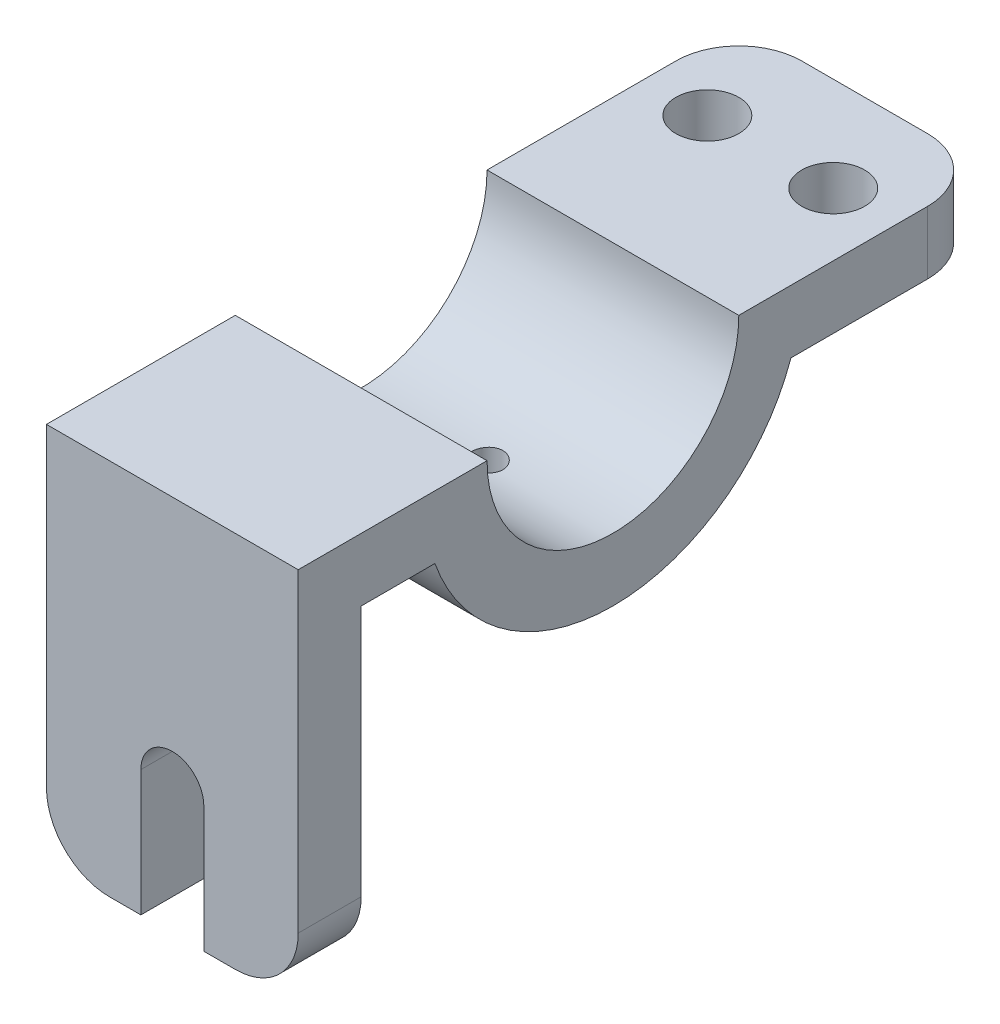
from build123d import *

# Parameters (mm, degrees)
BOSS_EXTRUDE1_DEPTH = 50.8
CUT_EXTRUDE1_DEPTH  = 22.86
CUT_EXTRUDE2_DEPTH  = 22.86
CUT_EXTRUDE3_DEPTH  = 22.86
SKETCH6_R           = 3.175
CUT_EXTRUDE4_DEPTH  = 60.96
CUT_EXTRUDE5_DEPTH  = 30.48
CUT_EXTRUDE6_DEPTH  = 30.48
SKETCH10_R          = 6.35
CUT_EXTRUDE7_DEPTH  = 30.48


with BuildPart() as part:
    # Sketch2 → Boss-Extrude1 (new body)
    with BuildSketch(Plane(origin=(0, 0, 0), x_dir=(0, 0, -1), z_dir=(1, 0, 0))):
        with BuildLine():
            Line((0, 0), (38.1, 0))
            ThreePointArc((38.1, 0), (63.5, -25.4), (88.9, 0))
            Line((88.9, 0), (139.7, 0))
            Line((139.7, 0), (139.7, -12.7))
            Line((139.7, -12.7), (99.421024484, -12.7))
            ThreePointArc((99.421024484, -12.7), (63.5, -38.1), (27.578975516, -12.7))
            Line((27.578975516, -12.7), (12.7, -12.7))
            Line((12.7, -12.7), (12.7, -76.2))
            Line((12.7, -76.2), (0, -76.2))
            Line((0, -76.2), (0, 0))
        make_face()
    extrude(amount=BOSS_EXTRUDE1_DEPTH)

    # Sketch3 → Cut-Extrude1 (cut)
    with BuildSketch(Plane.XY):
        with BuildLine():
            Line((50.8, -63.5), (50.8, -76.2))
            Line((50.8, -76.2), (38.1, -76.2))
            ThreePointArc((38.1, -76.2), (47.080256121, -72.480256121), (50.8, -63.5))
        make_face()
    extrude(amount=-CUT_EXTRUDE1_DEPTH, mode=Mode.SUBTRACT)

    # Sketch4 → Cut-Extrude2 (cut)
    with BuildSketch(Plane.XY):
        with BuildLine():
            Line((0, -63.5), (0, -76.2))
            Line((0, -76.2), (12.7, -76.2))
            ThreePointArc((12.7, -76.2), (3.719743879, -72.480256121), (0, -63.5))
        make_face()
    extrude(amount=-CUT_EXTRUDE2_DEPTH, mode=Mode.SUBTRACT)

    # Sketch5 → Cut-Extrude3 (cut)
    with BuildSketch(Plane.XY):
        with BuildLine():
            Line((19.05, -76.2), (19.05, -50.8))
            ThreePointArc((19.05, -50.8), (25.4, -44.45), (31.75, -50.8))
            Line((31.75, -50.8), (31.75, -76.2))
            Line((31.75, -76.2), (19.05, -76.2))
        make_face()
    extrude(amount=-CUT_EXTRUDE3_DEPTH, mode=Mode.SUBTRACT)

    # Sketch6 → Cut-Extrude4 (cut)
    with BuildSketch(Plane(origin=(0, 0, 0), x_dir=(1, 0, 0), z_dir=(0, 1, 0))):
        with Locations((25.4, 63.5)):
            Circle(SKETCH6_R)
    extrude(amount=-CUT_EXTRUDE4_DEPTH, mode=Mode.SUBTRACT)

    # Sketch7 → Cut-Extrude5 (cut)
    with BuildSketch(Plane(origin=(0, 0, 0), x_dir=(1, 0, 0), z_dir=(0, 1, 0))):
        with BuildLine():
            Line((0, 127), (0, 139.7))
            Line((0, 139.7), (12.7, 139.7))
            ThreePointArc((12.7, 139.7), (3.719743879, 135.980256121), (0, 127))
        make_face()
    extrude(amount=-CUT_EXTRUDE5_DEPTH, mode=Mode.SUBTRACT)

    # Sketch9 → Cut-Extrude6 (cut)
    with BuildSketch(Plane(origin=(0, 0, 0), x_dir=(1, 0, 0), z_dir=(0, 1, 0))):
        with BuildLine():
            Line((50.8, 127), (50.8, 139.7))
            Line((50.8, 139.7), (38.1, 139.7))
            ThreePointArc((38.1, 139.7), (47.080256121, 135.980256121), (50.8, 127))
        make_face()
    extrude(amount=-CUT_EXTRUDE6_DEPTH, mode=Mode.SUBTRACT)

    # Sketch10 → Cut-Extrude7 (cut)
    with BuildSketch(Plane(origin=(0, 0, 0), x_dir=(1, 0, 0), z_dir=(0, 1, 0))):
        with Locations((38.1, 120.65)):
            Circle(SKETCH10_R)
        with Locations((12.7, 120.65)):
            Circle(SKETCH10_R)
    extrude(amount=-CUT_EXTRUDE7_DEPTH, mode=Mode.SUBTRACT)


solid = part.part
